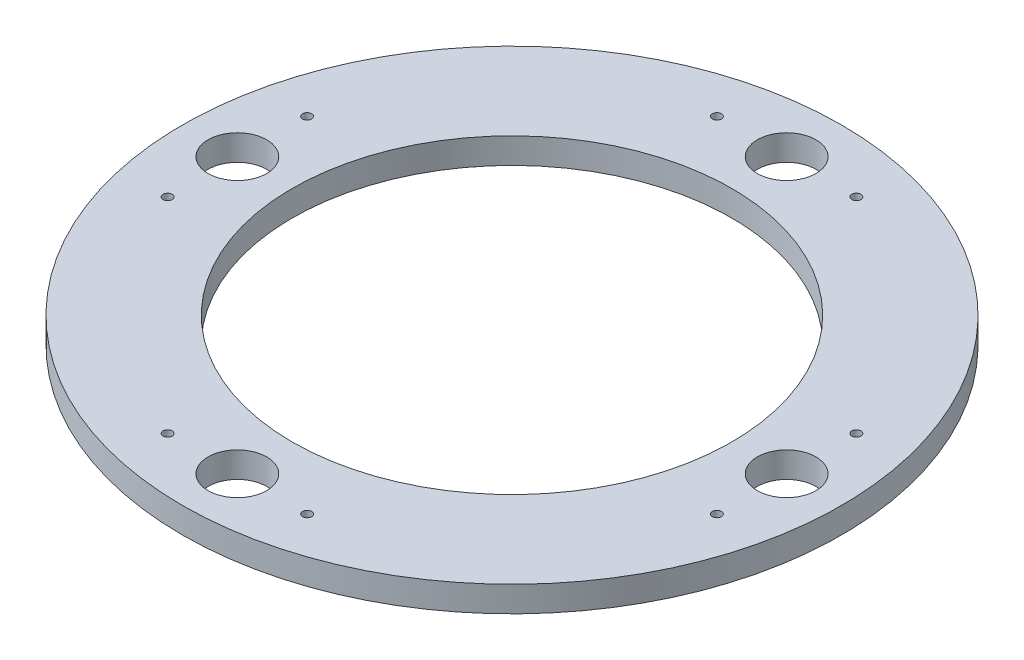
from build123d import *

# Parameters (mm, degrees)
SKETCH2_R             = 90
EXTRUDE1_DEPTH        = 7
SKETCH3_R             = 8
CUT_EXTRUDE1_DEPTH    = 8
M3X0_5_TAPPED_HOLE1_D = 2.5
CIRPATTERN1_COUNT     = 4
SKETCH8_R             = 60
CUT_EXTRUDE2_DEPTH    = 8


with BuildPart() as part:
    # Sketch2 → Extrude1 (new body)
    with BuildSketch(Plane(origin=(0, 0, 0), x_dir=(1, 0, 0), z_dir=(0, 1, 0))):
        Circle(SKETCH2_R)
    extrude(amount=EXTRUDE1_DEPTH)

    # Sketch3 → Cut-Extrude1 (cut, through all)
    with BuildSketch(Plane(origin=(0, 7, 0), x_dir=(1, 0, 0), z_dir=(0, 1, 0))):
        with Locations((0, 75)):
            Circle(SKETCH3_R)
    cut_extrude1 = extrude(amount=-CUT_EXTRUDE1_DEPTH, mode=Mode.SUBTRACT)

    # M3x0.5 Tapped Hole1 (through all)
    with Locations(Plane(origin=(0, 7, 0), x_dir=(1, 0, 0), z_dir=(0, 1, 0))):
        with Locations((-19.05, 75), (19.05, 75)):
            m3x0_5_tapped_hole1 = Hole(M3X0_5_TAPPED_HOLE1_D / 2)

    # CirPattern1: Cut-Extrude1, M3x0.5 Tapped Hole1 ×4 about axis
    cirpattern1_axis = Axis((0, 0, 0), (0, 1, 0))
    for i in range(1, CIRPATTERN1_COUNT):
        add(cut_extrude1.rotate(cirpattern1_axis, i * 360 / CIRPATTERN1_COUNT), mode=Mode.SUBTRACT)
        add(m3x0_5_tapped_hole1.rotate(cirpattern1_axis, i * 360 / CIRPATTERN1_COUNT), mode=Mode.SUBTRACT)

    # Sketch8 → Cut-Extrude2 (cut, through all)
    with BuildSketch(Plane(origin=(0, 7, 0), x_dir=(1, 0, 0), z_dir=(0, 1, 0))):
        Circle(SKETCH8_R)
    extrude(amount=-CUT_EXTRUDE2_DEPTH, mode=Mode.SUBTRACT)


solid = part.part
